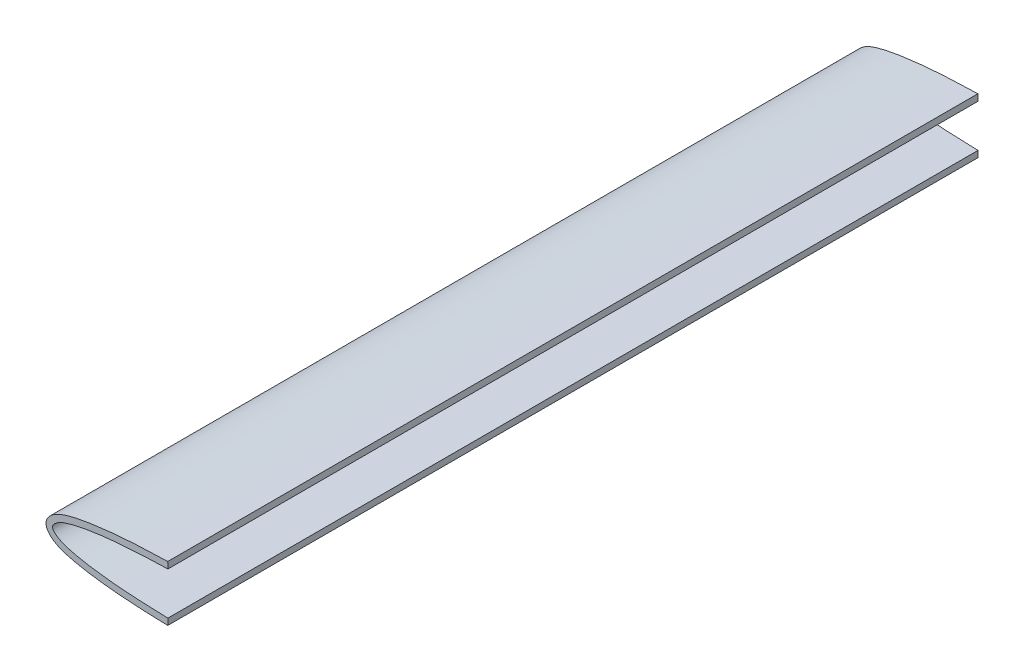
from build123d import *

# Parameters (mm, degrees)
BOSS_EXTRUDE1_DEPTH = 287.02


with BuildPart() as part:
    # Sketch1 → Boss-Extrude1 (new body)
    with BuildSketch(Plane.XY):
        with BuildLine():
            Line((40.894, 7.534423827), (40.842940477, 9.819853529))
            add(Edge.make_bspline(
                [(40.842940477, 9.819853529), (39.055963938, 9.77993011), (35.483537702, 9.674918974), (30.121954539, 9.429752425), (24.754681472, 9.076499869), (20.277636913, 8.668959487), (16.694015828, 8.248258293), (14.008902396, 7.879704381), (11.322377369, 7.450696677), (8.631336977, 6.940749768), (6.374711722, 6.42233794), (4.538165651, 5.892640846), (3.147579803, 5.412350109), (1.962804386, 4.901117894), (1.004595217, 4.382441404), (0.288845401, 3.925724992), (-0.421819233, 3.374435443), (-0.968913589, 2.857792368), (-1.44198383, 2.299098571), (-1.780491458, 1.79282249), (-2.053318394, 1.25570253), (-2.240539637, 0.619706765), (-2.308730182, 3.1e-08), (-2.240539635, -0.619706698), (-2.053318391, -1.255702461), (-1.780491456, -1.792822418), (-1.441983827, -2.299098499), (-0.968913587, -2.857792295), (-0.421819231, -3.37443537), (0.288845403, -3.925724919), (1.004595218, -4.382441331), (1.962804388, -4.90111782), (3.147579804, -5.412350036), (4.538165652, -5.892640773), (6.374711722, -6.422337868), (8.631336978, -6.940749697), (11.322377369, -7.450696607), (14.008902396, -7.879704312), (16.694015828, -8.248258225), (20.277636913, -8.66895942), (24.754681471, -9.076499804), (30.121954538, -9.429752363), (35.483537701, -9.674918915), (39.055963937, -9.779930051), (40.842940476, -9.819853472)],
                knots=[0.375677589, 0.375677589, 0.375677589, 0.375677589, 0.391217891, 0.406758192, 0.422298493, 0.437838795, 0.445608945, 0.453379096, 0.461149247, 0.468919397, 0.476689548, 0.480574623, 0.484459699, 0.488344774, 0.490287312, 0.492229849, 0.494172387, 0.496114925, 0.497086194, 0.498057462, 0.499028731, 0.499514366, 0.5, 0.500485634, 0.500971269, 0.501942538, 0.502913807, 0.503885075, 0.505827613, 0.507770151, 0.509712688, 0.511655226, 0.515540301, 0.519425377, 0.523310452, 0.531080603, 0.538850753, 0.546620904, 0.554391055, 0.562161205, 0.577701507, 0.593241808, 0.608782109, 0.624322411, 0.624322411, 0.624322411, 0.624322411], degree=3))
            Line((40.842940476, -9.819853472), (40.894, -7.534423769))
            add(Edge.make_bspline(
                [(40.894, 7.534423827), (39.808085712, 7.510163065), (37.220453829, 7.441753838), (33.204930627, 7.288203136), (28.926950367, 7.06433366), (24.887205136, 6.783394048), (21.10282442, 6.450138041), (17.591236568, 6.06164777), (14.36707854, 5.625329433), (11.442956945, 5.152430984), (8.831049911, 4.645070522), (6.53984232, 4.105006343), (4.580184408, 3.514050698), (2.956329666, 2.861257927), (1.683136206, 2.140990928), (0.767554785, 1.388873225), (0.195767807, 0.699527486), (-0.080108155, 3.8e-08), (0.195767807, -0.69952741), (0.767554785, -1.388873149), (1.683136205, -2.140990853), (2.956329665, -2.861257852), (4.580184407, -3.514050624), (6.539842319, -4.10500627), (8.831049908, -4.64507045), (11.442956943, -5.152430914), (14.367078537, -5.625329364), (17.591236565, -6.061647702), (21.102824417, -6.450137975), (24.887205132, -6.783393983), (28.926950364, -7.064333597), (33.204930624, -7.288203075), (37.220453826, -7.441753779), (39.808085711, -7.510163007), (40.894, -7.534423769)],
                knots=[0.375677589, 0.375677589, 0.375677589, 0.375677589, 0.385183441, 0.398331273, 0.410844637, 0.422672607, 0.433769314, 0.444090175, 0.453589412, 0.46224044, 0.470010037, 0.476870985, 0.482833353, 0.487908551, 0.492155164, 0.495592273, 0.498196359, 0.5, 0.501803641, 0.504407727, 0.507844836, 0.512091449, 0.517166647, 0.523129015, 0.529989963, 0.53775956, 0.546410588, 0.555909825, 0.566230686, 0.577327393, 0.589155363, 0.601668727, 0.614816559, 0.624322411, 0.624322411, 0.624322411, 0.624322411], degree=3))
        make_face()
    extrude(amount=BOSS_EXTRUDE1_DEPTH)


solid = part.part
